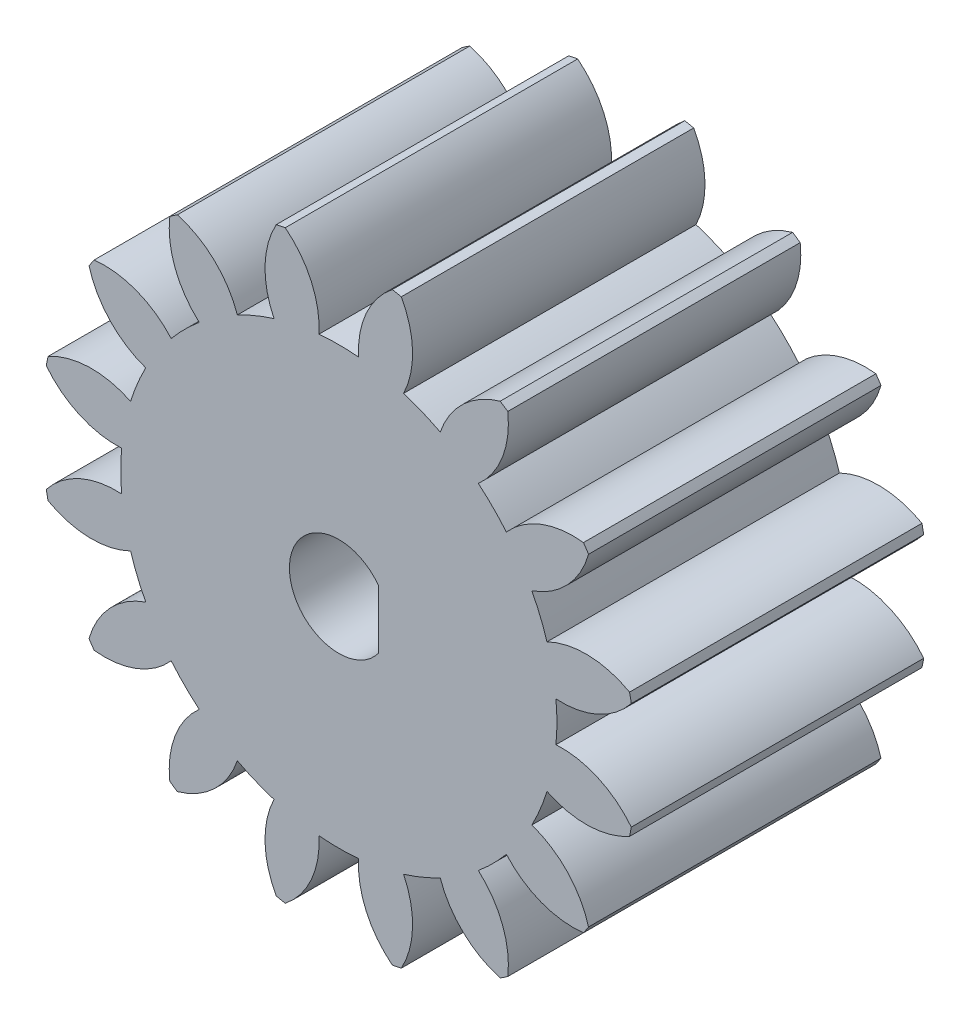
from build123d import *

# Parameters (mm, degrees)
SKETCH1_R           = 15
BOSS_EXTRUDE1_DEPTH = 14.75
CUT_EXTRUDE1_DEPTH  = 15.75
CIRPATTERN1_COUNT   = 16
CUT_EXTRUDE2_DEPTH  = 15.75


with BuildPart() as part:
    # Sketch1 → Boss-Extrude1 (new body)
    with BuildSketch(Plane.XY):
        Circle(SKETCH1_R)
    extrude(amount=BOSS_EXTRUDE1_DEPTH)

    # Sketch2 → Cut-Extrude1 (cut, through all)
    with BuildSketch(Plane.XY.offset(14.75)):
        with BuildLine():
            ThreePointArc((-1, 10.95445115), (0, 11), (1, 10.95445115))
            ThreePointArc((1, 10.95445115), (1.384034944, 13.063153145), (2.7, 14.754999153))
            ThreePointArc((2.7, 14.754999153), (0, 15), (-2.7, 14.754999153))
            ThreePointArc((-2.7, 14.754999153), (-1.384034944, 13.063153145), (-1, 10.95445115))
        make_face()
    cut_extrude1 = extrude(amount=-CUT_EXTRUDE1_DEPTH, mode=Mode.SUBTRACT)

    # CirPattern1: Cut-Extrude1 ×16 about axis
    cirpattern1_axis = Axis((0, 0, 0), (0, 0, 1))
    for i in range(1, CIRPATTERN1_COUNT):
        add(cut_extrude1.rotate(cirpattern1_axis, i * 360 / CIRPATTERN1_COUNT), mode=Mode.SUBTRACT)

    # Sketch3 → Cut-Extrude2 (cut, through all)
    with BuildSketch(Plane.XY.offset(14.75)):
        with BuildLine():
            Line((2.0058, 1.47542074), (2.0058, -1.47542074))
            ThreePointArc((2.0058, -1.47542074), (-2.49, 0), (2.0058, 1.47542074))
        make_face()
    extrude(amount=-CUT_EXTRUDE2_DEPTH, mode=Mode.SUBTRACT)


solid = part.part
